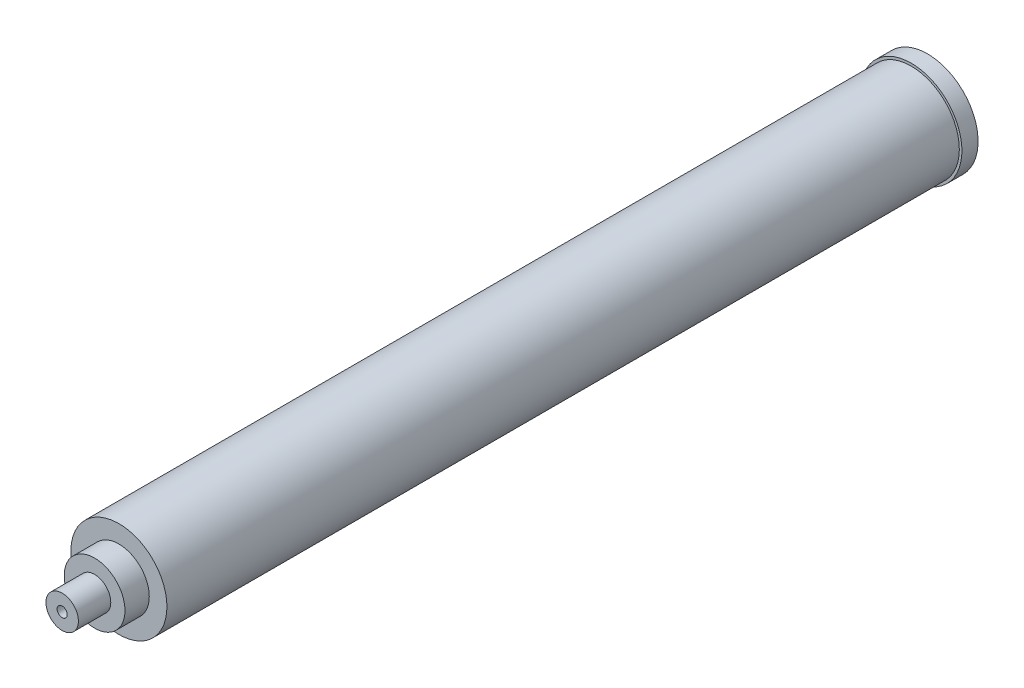
from build123d import *

# Parameters (mm, degrees)
SKETCH1_R                   = 37.6555
BOSS_EXTRUDE1_DEPTH         = 621.03
SKETCH2_R                   = 39.6621
BOSS_EXTRUDE2_DEPTH         = 12.7
SKETCH4_R                   = 23.8125
BOSS_EXTRUDE4_DEPTH         = 19.05
SKETCH5_R                   = 12.7
BOSS_EXTRUDE5_DEPTH         = 25.4
F_3_8_16_TAPPED_HOLE1_D     = 7.9375
F_3_8_16_TAPPED_HOLE1_DEPTH = 25.4
F_3_8_16_TAPPED_HOLE1_TIP   = 2.384665582


with BuildPart() as part:
    # Sketch1 → Boss-Extrude1 (new body)
    with BuildSketch(Plane.XY):
        Circle(SKETCH1_R)
    extrude(amount=BOSS_EXTRUDE1_DEPTH)

    # Sketch2 → Boss-Extrude2 (add)
    with BuildSketch(Plane(origin=(0, 0, 0), x_dir=(-1, 0, 0), z_dir=(0, 0, -1))):
        Circle(SKETCH2_R)
    extrude(amount=BOSS_EXTRUDE2_DEPTH)

    # Sketch4 → Boss-Extrude4 (add)
    with BuildSketch(Plane.XY.offset(621.03)):
        Circle(SKETCH4_R)
    extrude(amount=BOSS_EXTRUDE4_DEPTH)

    # Sketch5 → Boss-Extrude5 (add)
    with BuildSketch(Plane.XY.offset(640.08)):
        Circle(SKETCH5_R)
    extrude(amount=BOSS_EXTRUDE5_DEPTH)

    # 3/8-16 Tapped Hole1
    with Locations(Plane.XY.offset(665.48)):
        with Locations((0, 0)):
            Hole(F_3_8_16_TAPPED_HOLE1_D / 2, depth=F_3_8_16_TAPPED_HOLE1_DEPTH)
            with Locations((0, 0, -(F_3_8_16_TAPPED_HOLE1_DEPTH + F_3_8_16_TAPPED_HOLE1_TIP / 2))):  # 118° drill point
                Cone(0, F_3_8_16_TAPPED_HOLE1_D / 2, F_3_8_16_TAPPED_HOLE1_TIP, mode=Mode.SUBTRACT)


solid = part.part
